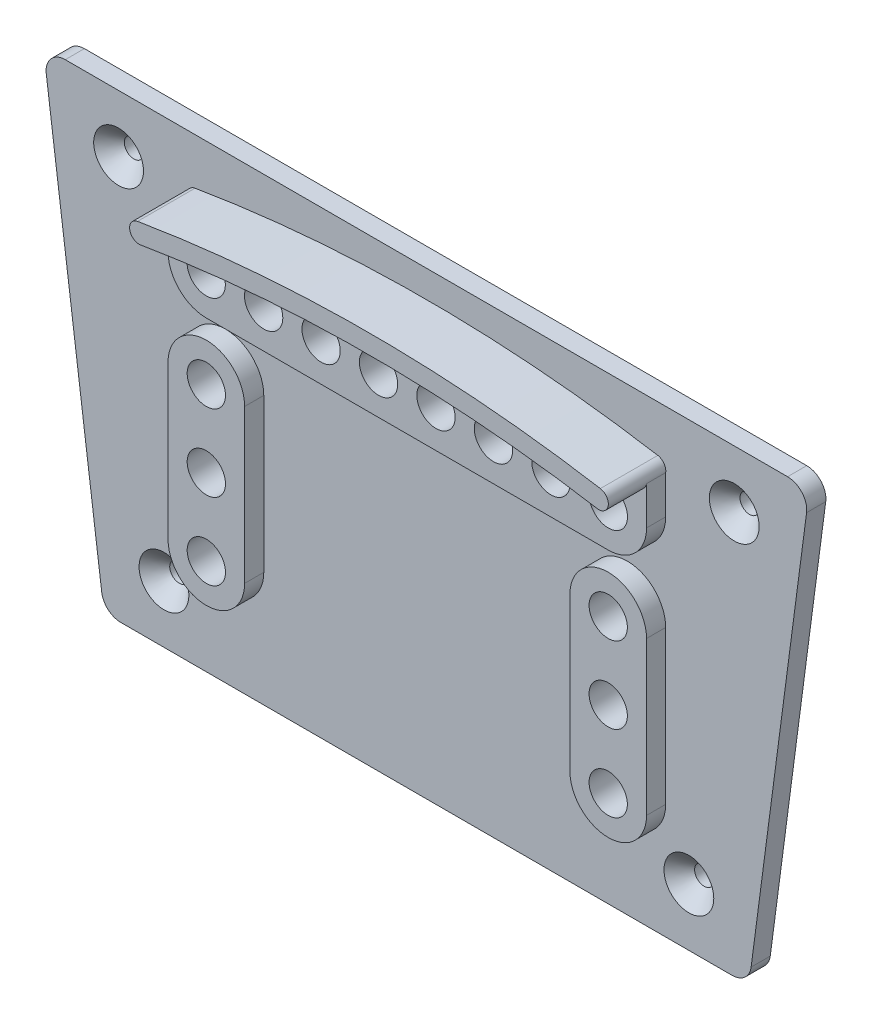
from build123d import *

# Parameters (mm, degrees)
BOSS_EXTRUDE1_DEPTH      = 3.175
BOSS_EXTRUDE2_DEPTH      = 3.175
SKETCH2_R                = 3.175
BOSS_EXTRUDE3_DEPTH      = 6.35
BOSS_EXTRUDE4_DEPTH      = 12.7
SKETCH2_4_R              = 3.175
CUT_EXTRUDE1_DEPTH       = 76.134213245
CUT_EXTRUDE1_DEPTH_BACK  = 76.134213245
FILLET1_R                = 6.35
SKETCH4_R                = 3.175
BOSS_EXTRUDE5_DEPTH      = 6.35
SKETCH4_2_R              = 3.175
CUT_EXTRUDE2_DEPTH       = 76.134213245
CUT_EXTRUDE2_DEPTH_BACK  = 76.134213245
BOSS_EXTRUDE6_DEPTH      = 38.1
BOSS_EXTRUDE7_START      = -38.1
BOSS_EXTRUDE7_DEPTH      = 6.35
BOSS_EXTRUDE11_REACH     = 88.369
SKETCH5_R                = 1.5875
SKETCH5_4_R              = 1.5875
CUT_EXTRUDE9_DEPTH       = 87.36933773
CUT_EXTRUDE9_DEPTH_BACK  = 87.36933773
SKETCH6_R                = 6.35
CUT_EXTRUDE10_DEPTH      = 6.35
CUT_EXTRUDE10_DEPTH_BACK = 510.682305539
CHAMFER1_SIZE            = 2.54
FILLET2_R                = 3.175
FILLET3_R                = 3.175


with BuildPart() as part:
    # Sketch1 → Boss-Extrude1 (new body)
    with BuildSketch(Plane.XY):
        Polygon((-53.468079684, -38.1), (53.468079684, -38.1), (63.5, 38.1), (-63.5, 38.1), align=None)
        Polygon((47.899279144, -31.75), (56.259212741, 31.75), (-56.259212741, 31.75), (-47.899279144, -31.75), align=None, mode=Mode.SUBTRACT)
        Polygon((-47.899279144, -31.75), (47.899279144, -31.75), (56.259212741, 31.75), (-56.259212741, 31.75), align=None)
    extrude(amount=BOSS_EXTRUDE1_DEPTH)

    # Sketch1_3 → Boss-Extrude2 (add)
    with BuildSketch(Plane.XY):
        Polygon((-47.899279144, -31.75), (47.899279144, -31.75), (56.259212741, 31.75), (-56.259212741, 31.75), align=None)
    extrude(amount=-BOSS_EXTRUDE2_DEPTH)

    # Sketch2 → Boss-Extrude3 (add)
    with BuildSketch(Plane.XY):
        with BuildLine():
            ThreePointArc((-37.837241379, 27.272155172), (-39.021250412, 27.544911403), (-39.665603448, 28.575))
            Line((-39.665603448, 28.575), (-39.665603448, 15.875))
            Line((-39.665603448, 15.875), (39.665603448, 15.875))
            Line((39.665603448, 15.875), (39.665603448, 28.575))
            ThreePointArc((39.665603448, 28.575), (39.021250412, 27.544911403), (37.837241379, 27.272155172))
            ThreePointArc((37.837241379, 27.272155172), (0, 30.425258621), (-37.837241379, 27.272155172))
        make_face()
        with Locations((-33.3375, 22.225)):
            Circle(SKETCH2_R, mode=Mode.SUBTRACT)
        with Locations((-23.8125, 22.225)):
            Circle(SKETCH2_R, mode=Mode.SUBTRACT)
        with Locations((-14.2875, 22.225)):
            Circle(SKETCH2_R, mode=Mode.SUBTRACT)
        with Locations((-4.7625, 22.225)):
            Circle(SKETCH2_R, mode=Mode.SUBTRACT)
        with Locations((4.7625, 22.225)):
            Circle(SKETCH2_R, mode=Mode.SUBTRACT)
        with Locations((14.2875, 22.225)):
            Circle(SKETCH2_R, mode=Mode.SUBTRACT)
        with Locations((23.8125, 22.225)):
            Circle(SKETCH2_R, mode=Mode.SUBTRACT)
        with Locations((33.3375, 22.225)):
            Circle(SKETCH2_R, mode=Mode.SUBTRACT)
        with Locations((-33.3375, 22.225)):
            Circle(SKETCH2_R)
        with Locations((-23.8125, 22.225)):
            Circle(SKETCH2_R)
        with Locations((-14.2875, 22.225)):
            Circle(SKETCH2_R)
        with Locations((-4.7625, 22.225)):
            Circle(SKETCH2_R)
        with Locations((4.7625, 22.225)):
            Circle(SKETCH2_R)
        with Locations((14.2875, 22.225)):
            Circle(SKETCH2_R)
        with Locations((23.8125, 22.225)):
            Circle(SKETCH2_R)
        with Locations((33.3375, 22.225)):
            Circle(SKETCH2_R)
        with BuildLine():
            ThreePointArc((-37.837241379, 27.272155172), (0, 30.425258621), (37.837241379, 27.272155172))
            ThreePointArc((37.837241379, 27.272155172), (39.665603448, 28.575), (38.362758621, 30.403362069))
            ThreePointArc((38.362758621, 30.403362069), (0, 33.600258621), (-38.362758621, 30.403362069))
            ThreePointArc((-38.362758621, 30.403362069), (-39.665603448, 28.575), (-37.837241379, 27.272155172))
        make_face()
    extrude(amount=BOSS_EXTRUDE3_DEPTH)

    # Sketch2_3 → Boss-Extrude4 (add)
    with BuildSketch(Plane.XY):
        with BuildLine():
            ThreePointArc((-37.837241379, 27.272155172), (0, 30.425258621), (37.837241379, 27.272155172))
            ThreePointArc((37.837241379, 27.272155172), (39.665603448, 28.575), (38.362758621, 30.403362069))
            ThreePointArc((38.362758621, 30.403362069), (0, 33.600258621), (-38.362758621, 30.403362069))
            ThreePointArc((-38.362758621, 30.403362069), (-39.665603448, 28.575), (-37.837241379, 27.272155172))
        make_face()
    extrude(amount=BOSS_EXTRUDE4_DEPTH)

    # Sketch2_4 → Cut-Extrude1 (cut, two sides)
    with BuildSketch(Plane.XY) as cut_extrude1_sk:
        with Locations((-33.3375, 22.225)):
            Circle(SKETCH2_4_R)
        with Locations((-23.8125, 22.225)):
            Circle(SKETCH2_4_R)
        with Locations((-14.2875, 22.225)):
            Circle(SKETCH2_4_R)
        with Locations((-4.7625, 22.225)):
            Circle(SKETCH2_4_R)
        with Locations((4.7625, 22.225)):
            Circle(SKETCH2_4_R)
        with Locations((14.2875, 22.225)):
            Circle(SKETCH2_4_R)
        with Locations((23.8125, 22.225)):
            Circle(SKETCH2_4_R)
        with Locations((33.3375, 22.225)):
            Circle(SKETCH2_4_R)
    extrude(amount=CUT_EXTRUDE1_DEPTH, mode=Mode.SUBTRACT)
    extrude(cut_extrude1_sk.sketch, amount=-CUT_EXTRUDE1_DEPTH_BACK, mode=Mode.SUBTRACT)

    # Fillet1
    fillet1_edges = [part.edges().sort_by_distance(p)[0] for p in [
        (39.665603448, 15.875, 4.7625),
        (-39.665603448, 15.875, 4.7625),
    ]]
    fillet(fillet1_edges, radius=FILLET1_R)

    # Sketch4 → Boss-Extrude5 (add)
    with BuildSketch(Plane.XY):
        with BuildLine():
            Line((-26.965603448, 6.35), (-26.965603448, -19.05))
            ThreePointArc((-26.965603448, -19.05), (-33.315603448, -25.4), (-39.665603448, -19.05))
            Line((-39.665603448, -19.05), (-39.665603448, 6.35))
            ThreePointArc((-39.665603448, 6.35), (-33.315603448, 12.7), (-26.965603448, 6.35))
        make_face()
        with Locations((-33.315603448, 6.35)):
            Circle(SKETCH4_R, mode=Mode.SUBTRACT)
        with Locations((-33.315603448, -6.35)):
            Circle(SKETCH4_R, mode=Mode.SUBTRACT)
        with Locations((-33.315603448, -19.05)):
            Circle(SKETCH4_R, mode=Mode.SUBTRACT)
        with BuildLine():
            Line((39.665603448, 6.35), (39.665603448, -19.05))
            ThreePointArc((39.665603448, -19.05), (33.315603448, -25.4), (26.965603448, -19.05))
            Line((26.965603448, -19.05), (26.965603448, 6.35))
            ThreePointArc((26.965603448, 6.35), (33.315603448, 12.7), (39.665603448, 6.35))
        make_face()
        with Locations((33.315603448, 6.35)):
            Circle(SKETCH4_R, mode=Mode.SUBTRACT)
        with Locations((33.315603448, -6.35)):
            Circle(SKETCH4_R, mode=Mode.SUBTRACT)
        with Locations((33.315603448, -19.05)):
            Circle(SKETCH4_R, mode=Mode.SUBTRACT)
    extrude(amount=BOSS_EXTRUDE5_DEPTH)

    # Sketch4_2 → Cut-Extrude2 (cut, two sides)
    with BuildSketch(Plane.XY) as cut_extrude2_sk:
        with Locations((-33.315603448, 6.35)):
            Circle(SKETCH4_2_R)
        with Locations((-33.315603448, -6.35)):
            Circle(SKETCH4_2_R)
        with Locations((-33.315603448, -19.05)):
            Circle(SKETCH4_2_R)
        with Locations((33.315603448, -19.05)):
            Circle(SKETCH4_2_R)
        with Locations((33.315603448, -6.35)):
            Circle(SKETCH4_2_R)
        with Locations((33.315603448, 6.35)):
            Circle(SKETCH4_2_R)
    extrude(amount=CUT_EXTRUDE2_DEPTH, mode=Mode.SUBTRACT)
    extrude(cut_extrude2_sk.sketch, amount=-CUT_EXTRUDE2_DEPTH_BACK, mode=Mode.SUBTRACT)

    # Sketch5_4 → Cut-Extrude9 (cut, two sides)
    with BuildSketch(Plane.XY) as cut_extrude9_sk:
        with Locations((-51.037620636, 28.575)):
            Circle(SKETCH5_4_R)
        with Locations((-43.513680399, -28.575)):
            Circle(SKETCH5_4_R)
        with Locations((43.513680399, -28.575)):
            Circle(SKETCH5_4_R)
        with Locations((51.037620636, 28.575)):
            Circle(SKETCH5_4_R)
    extrude(amount=CUT_EXTRUDE9_DEPTH, mode=Mode.SUBTRACT)
    extrude(cut_extrude9_sk.sketch, amount=-CUT_EXTRUDE9_DEPTH_BACK, mode=Mode.SUBTRACT)

    # Chamfer1
    chamfer1_edges = [part.edges().sort_by_distance(p)[0] for p in [
        (-52.625120636, 28.575, 3.175),
        (-45.101180399, -28.575, 3.175),
        (41.926180399, -28.575, 3.175),
        (49.450120636, 28.575, 3.175),
    ]]
    chamfer(chamfer1_edges, length=CHAMFER1_SIZE)

    # Fillet3
    fillet3_edges = [part.edges().sort_by_distance(p)[0] for p in [
        (-53.468079684, -38.1, 1.5875),
        (-63.5, 38.1, 1.5875),
        (63.5, 38.1, 1.5875),
        (53.468079684, -38.1, 1.5875),
    ]]
    fillet(fillet3_edges, radius=FILLET3_R)


with BuildPart() as body_2:
    # Sketch1_4 → Boss-Extrude6 (new body)
    with BuildSketch(Plane.XY):
        Polygon((-53.468079684, -38.1), (53.468079684, -38.1), (63.5, 38.1), (-63.5, 38.1), align=None)
        Polygon((47.899279144, -31.75), (56.259212741, 31.75), (-56.259212741, 31.75), (-47.899279144, -31.75), align=None, mode=Mode.SUBTRACT)
    extrude(amount=-BOSS_EXTRUDE6_DEPTH)

    # Sketch1_5 → Boss-Extrude7 (add)
    with BuildSketch(Plane.XY.offset(BOSS_EXTRUDE7_START)):
        Polygon((-53.468079684, -38.1), (53.468079684, -38.1), (63.5, 38.1), (-63.5, 38.1), align=None)
        Polygon((47.899279144, -31.75), (56.259212741, 31.75), (-56.259212741, 31.75), (-47.899279144, -31.75), align=None, mode=Mode.SUBTRACT)
        Polygon((-47.899279144, -31.75), (47.899279144, -31.75), (56.259212741, 31.75), (-56.259212741, 31.75), align=None)
    extrude(amount=-BOSS_EXTRUDE7_DEPTH)

    # Sketch5 → Boss-Extrude11 (add, up to next)
    with BuildSketch(Plane.XY, mode=Mode.PRIVATE) as boss_extrude11_sk1:
        with BuildLine():
            Line((-56.259212741, 31.75), (-55.211149786, 23.789171499))
            ThreePointArc((-55.211149786, 23.789171499), (-48.408876649, 22.794670853), (-44.687620636, 28.575))
            ThreePointArc((-44.687620636, 28.575), (-44.903991639, 30.218500936), (-45.538359322, 31.75))
            Line((-45.538359322, 31.75), (-56.259212741, 31.75))
        make_face()
        with Locations((-51.037620636, 28.575)):
            Circle(SKETCH5_R, mode=Mode.SUBTRACT)
    boss_extrude11_tool1 = extrude(boss_extrude11_sk1.sketch, amount=-BOSS_EXTRUDE11_REACH, mode=Mode.PRIVATE) - body_2.part
    # Sketch5 → Boss-Extrude11 (add, up to next)
    with BuildSketch(Plane.XY, mode=Mode.PRIVATE) as boss_extrude11_sk2:
        with BuildLine():
            Line((-48.783663554, -25.03243348), (-47.899279144, -31.75))
            Line((-47.899279144, -31.75), (-38.014419085, -31.75))
            ThreePointArc((-38.014419085, -31.75), (-37.380051402, -30.218500936), (-37.163680399, -28.575))
            ThreePointArc((-37.163680399, -28.575), (-41.661910034, -22.501002427), (-48.783663554, -25.03243348))
        make_face()
        with Locations((-43.513680399, -28.575)):
            Circle(SKETCH5_R, mode=Mode.SUBTRACT)
    boss_extrude11_tool2 = extrude(boss_extrude11_sk2.sketch, amount=-BOSS_EXTRUDE11_REACH, mode=Mode.PRIVATE) - body_2.part
    # Sketch5 → Boss-Extrude11 (add, up to next)
    with BuildSketch(Plane.XY, mode=Mode.PRIVATE) as boss_extrude11_sk3:
        with BuildLine():
            ThreePointArc((48.783663554, -25.03243348), (40.152941328, -23.187242313), (38.014419085, -31.75))
            Line((38.014419085, -31.75), (47.899279144, -31.75))
            Line((47.899279144, -31.75), (48.783663554, -25.03243348))
        make_face()
        with Locations((43.513680399, -28.575)):
            Circle(SKETCH5_R, mode=Mode.SUBTRACT)
    boss_extrude11_tool3 = extrude(boss_extrude11_sk3.sketch, amount=-BOSS_EXTRUDE11_REACH, mode=Mode.PRIVATE) - body_2.part
    # Sketch5 → Boss-Extrude11 (add, up to next)
    with BuildSketch(Plane.XY, mode=Mode.PRIVATE) as boss_extrude11_sk4:
        with BuildLine():
            ThreePointArc((45.538359322, 31.75), (47.002389658, 23.671999801), (55.211149786, 23.789171499))
            Line((55.211149786, 23.789171499), (56.259212741, 31.75))
            Line((56.259212741, 31.75), (45.538359322, 31.75))
        make_face()
        with Locations((51.037620636, 28.575)):
            Circle(SKETCH5_R, mode=Mode.SUBTRACT)
    boss_extrude11_tool4 = extrude(boss_extrude11_sk4.sketch, amount=-BOSS_EXTRUDE11_REACH, mode=Mode.PRIVATE) - body_2.part
    add(boss_extrude11_tool1.solids().sort_by_distance((-48.470922, 22.931101, 0))[0])
    add(boss_extrude11_tool2.solids().sort_by_distance((-48.192507, -28.371605, 0))[0])
    add(boss_extrude11_tool3.solids().sort_by_distance((40.232461, -23.314724, 0))[0])
    add(boss_extrude11_tool4.solids().sort_by_distance((47.097631, 23.787723, 0))[0])

    # Sketch6 → Cut-Extrude10 (cut, two sides)
    with BuildSketch(Plane(origin=(-2.773412859, -465.296548287, 0), x_dir=(0, 0, -1), z_dir=(-0.9914448613738105, 0.1305261922200517, 0))) as cut_extrude10_sk:
        with Locations(Location((25.4, -469.31157386, 0), (0, 0, 90))):
            Circle(SKETCH6_R)
    extrude(amount=CUT_EXTRUDE10_DEPTH, mode=Mode.SUBTRACT)
    extrude(cut_extrude10_sk.sketch, amount=-CUT_EXTRUDE10_DEPTH_BACK, mode=Mode.SUBTRACT)

    # Fillet2
    fillet2_edges = [body_2.edges().sort_by_distance(p)[0] for p in [
        (-53.468079684, -38.1, -22.225),
        (-63.5, 38.1, -22.225),
        (63.5, 38.1, -22.225),
        (53.468079684, -38.1, -22.225),
        (0, -38.1, -44.45),
        (58.484039842, 0, -44.45),
        (-58.484039842, 0, -44.45),
        (0, 38.1, -44.45),
    ]]
    fillet(fillet2_edges, radius=FILLET2_R)


solid = part.part
